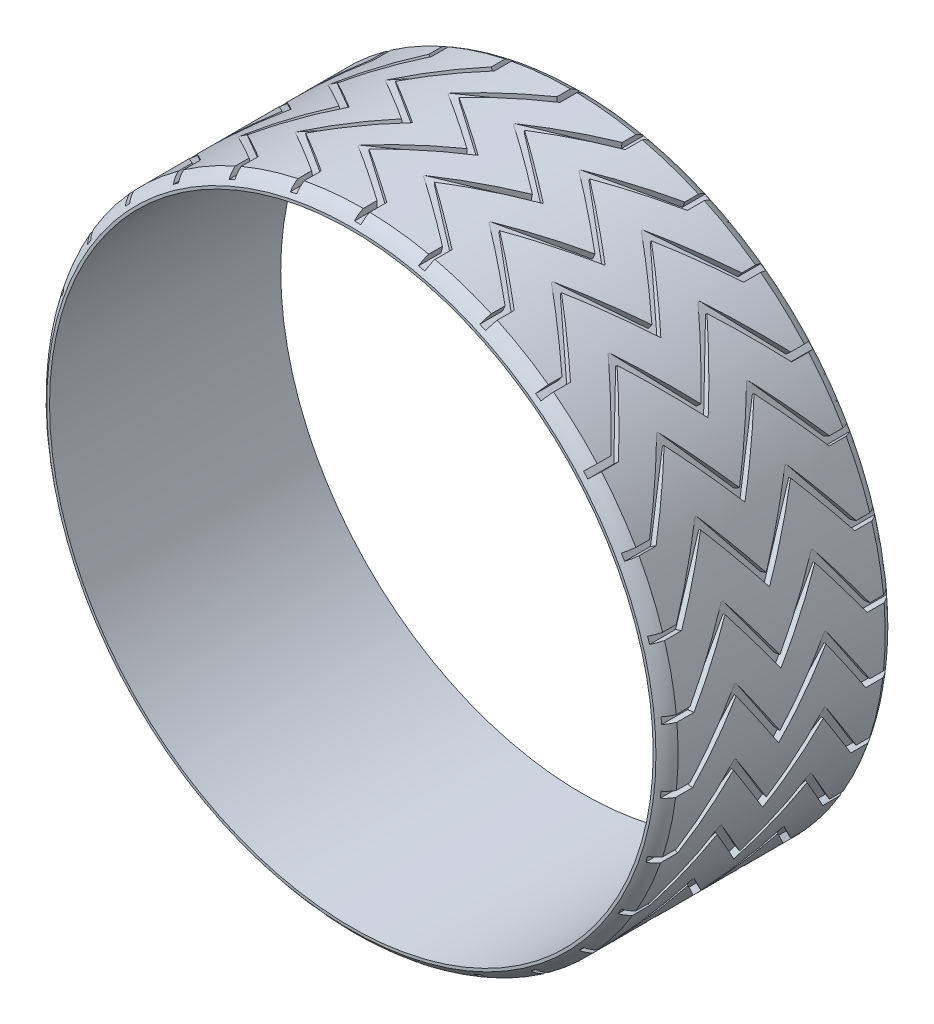
from build123d import *

# Parameters (mm, degrees)
SKETCH1_R           = 24.5
SKETCH1_R_2         = 23.5
BOSS_EXTRUDE1_DEPTH = 9
CUT_EXTRUDE2_DEPTH  = 1.5
CIRPATTERN3_COUNT   = 30


with BuildPart() as part:
    # Sketch1 → Boss-Extrude1 (new, symmetric)
    with BuildSketch(Plane.XY):
        Circle(SKETCH1_R)
        Circle(SKETCH1_R_2, mode=Mode.SUBTRACT)
    extrude(amount=BOSS_EXTRUDE1_DEPTH, both=True)

    # Sketch2_3 → Cut-Extrude2 (cut)
    with BuildSketch(Plane(origin=(0, 25.5, 0), x_dir=(1, 0, 0), z_dir=(0, 1, 0))):
        Polygon((0, -9), (0, -7), (-5, -3.5), (0, 0), (-5, 3.5), (0, 7), (0, 9), (0.5, 9), (0.5, 6.739672219), (-4.12810317, 3.5), (0.87189683, 0), (-4.12810317, -3.5), (0.5, -6.739672219), (0.5, -9), align=None)
    cut_extrude2 = extrude(amount=-CUT_EXTRUDE2_DEPTH, mode=Mode.SUBTRACT)

    # CirPattern3: Cut-Extrude2 ×30 about axis
    cirpattern3_axis = Axis((0, 0, 0), (0, 0, 1))
    for i in range(1, CIRPATTERN3_COUNT):
        add(cut_extrude2.rotate(cirpattern3_axis, i * 360 / CIRPATTERN3_COUNT), mode=Mode.SUBTRACT)

    # Sketch3 → Cut-Revolve1 (revolve, cut)
    with BuildSketch(Plane(origin=(0, 0, 0), x_dir=(0, 0, -1), z_dir=(1, 0, 0)), mode=Mode.PRIVATE) as cut_revolve1_sk:
        with BuildLine():
            Line((-9, 24.713018949), (-7.233720402, 24.713018949))
            add(Edge.make_bspline(
                [(-9, 23.713018949), (-8.359582357, 24.610039011), (-7.233720402, 24.713018949)],
                knots=[0, 0, 0, 1, 1, 1], degree=2))
            Line((-9, 23.713018949), (-9, 24.713018949))
        make_face()
        with BuildLine():
            Line((9, 24.713018949), (9, 23.713018949))
            add(Edge.make_bspline(
                [(9, 23.713018949), (8.359582357, 24.610039011), (7.233720402, 24.713018949)],
                knots=[0, 0, 0, 1, 1, 1], degree=2))
            Line((7.233720402, 24.713018949), (9, 24.713018949))
        make_face()
    revolve(cut_revolve1_sk.sketch.rotate(Axis((0, 0, 0), (0, 0, -1)), 90), axis=Axis((0, 0, 0), (0, 0, -1)), mode=Mode.SUBTRACT)


solid = part.part
